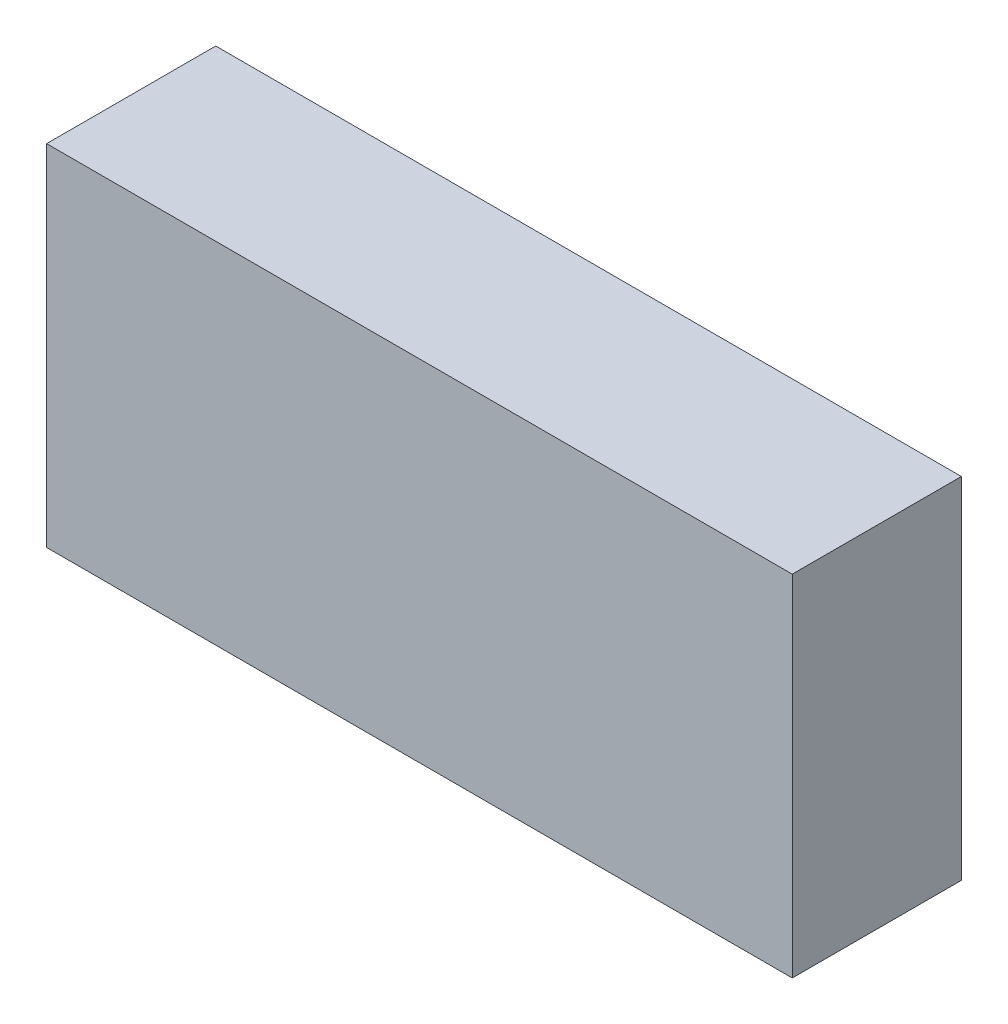
from build123d import *

# Parameters (mm, degrees)
SKETCH1_W           = 194
SKETCH1_H           = 91
BOSS_EXTRUDE1_DEPTH = 44


with BuildPart() as part:
    # Sketch1 → Boss-Extrude1 (new body)
    with BuildSketch(Plane.XY):
        Rectangle(SKETCH1_W, SKETCH1_H)
    extrude(amount=BOSS_EXTRUDE1_DEPTH)


solid = part.part
